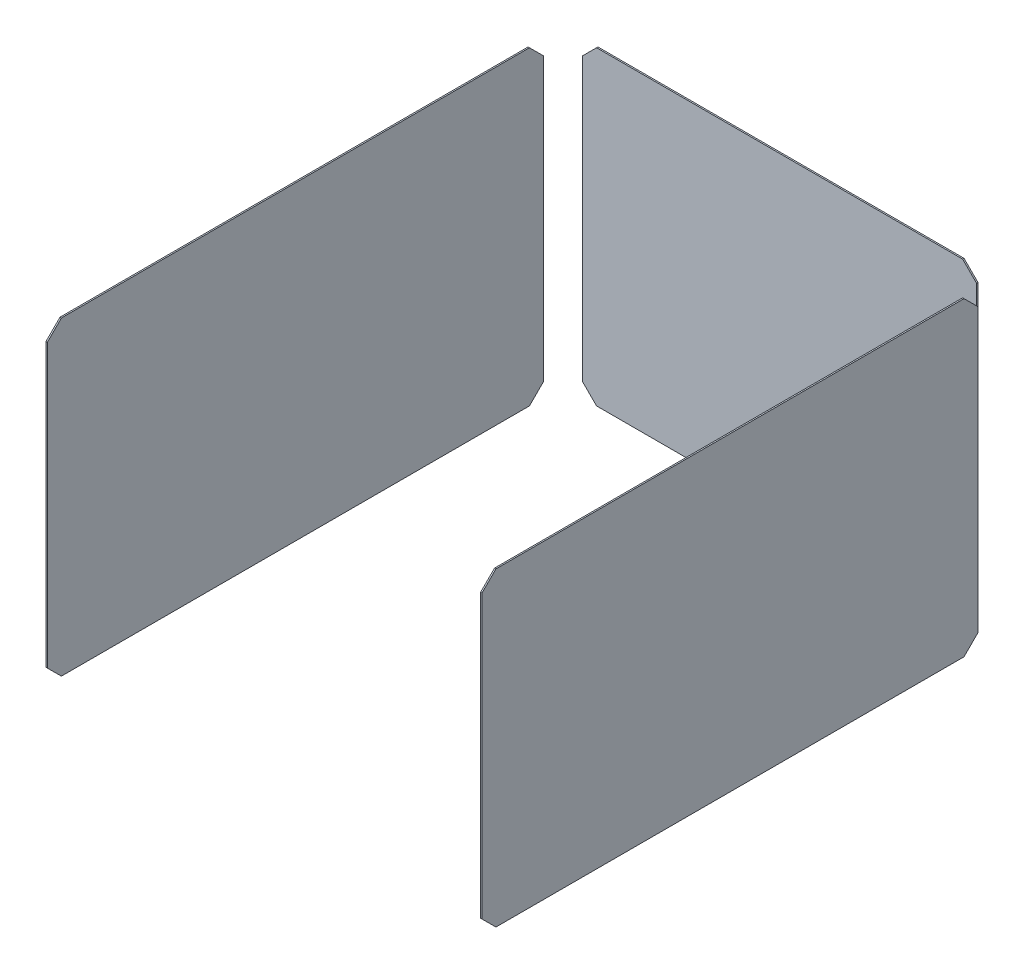
from build123d import *

# Parameters (mm, degrees)
ESQUISSE1_W             = 3120
ESQUISSE1_H             = 2520
ESQUISSE1_W_2           = 3100
ESQUISSE1_H_2           = 2500
EXTRU_MINCE1_DEPTH      = 3700
ESQUISSE3_W             = 3100
ESQUISSE3_H             = 2500
BOSS_EXTRU_1_DEPTH      = 10
ENL_V_MAT_EXTRU_1_DEPTH = 4000
ESQUISSE4_W             = 190.988555417
ESQUISSE4_H             = 256.995888021
ENL_V_MAT_EXTRU_2_DEPTH = 3025.2
CHANFREIN1_SIZE         = 100
CHANFREIN2_SIZE         = 100
CHANFREIN3_SIZE         = 100


with BuildPart() as part:
    # Esquisse1 → Extru.-Mince1 (new body)
    with BuildSketch(Plane.XY):
        with Locations((1550, 1250)):
            Rectangle(ESQUISSE1_W, ESQUISSE1_H)
        with Locations((1550, 1250)):
            Rectangle(ESQUISSE1_W_2, ESQUISSE1_H_2, mode=Mode.SUBTRACT)
    extrude(amount=-EXTRU_MINCE1_DEPTH)

    # Esquisse3 → Boss.-Extru.1 (add)
    with BuildSketch(Plane(origin=(0, 0, -3700), x_dir=(-1, 0, 0), z_dir=(0, 0, -1))):
        with Locations((-1550, 1250)):
            Rectangle(ESQUISSE3_W, ESQUISSE3_H)
    extrude(amount=-BOSS_EXTRU_1_DEPTH)

    # Esquisse2 → Enlèv. mat.-Extru.1 (cut)
    with BuildSketch(Plane.XY):
        Polygon((-60, 2560), (140, 2560), (140, 2500), (2960, 2500), (2960, 2560), (3160, 2560), (3160, 2360), (2960, 2360), (140, 2360), (-60, 2360), align=None)
        Polygon((2960, 140), (140, 140), (-60, 140), (-60, -60), (140, -60), (140, 0), (2960, 0), (2960, -60), (3160, -60), (3160, 140), align=None)
    extrude(amount=-ENL_V_MAT_EXTRU_1_DEPTH, mode=Mode.SUBTRACT)


with BuildPart() as enl_v_mat_extru_1_kept_piece:
    # of the separate pieces the step leaves, the one the design keeps (enl_v_mat_extru_1_pieces_kept)
    add(part.part.solids().sort_by_distance((3110, 140, 0))[0])

    # Esquisse4 → Enlèv. mat.-Extru.2 (cut)
    with BuildSketch(Plane(origin=(0, 2360, 0), x_dir=(1, 0, 0), z_dir=(0, 1, 0))):
        with Locations((44.505722291, 3678.49794401)):
            Rectangle(ESQUISSE4_W, ESQUISSE4_H)
        with Locations((3055.494277708, 3678.49794401)):
            Rectangle(ESQUISSE4_W, ESQUISSE4_H)
    extrude(amount=-ENL_V_MAT_EXTRU_2_DEPTH, mode=Mode.SUBTRACT)


with BuildPart() as enl_v_mat_extru_2_piece_1:
    # of the separate pieces the step leaves, piece 1, a body of its own (enl_v_mat_extru_2_pieces)
    add(enl_v_mat_extru_1_kept_piece.part.solids().sort_by_distance((3110, 140, 0))[0])

    # Chanfrein3
    chanfrein3_edges = [enl_v_mat_extru_2_piece_1.edges().sort_by_distance(p)[0] for p in [
        (3105, 2360, 0),
        (3105, 140, -3550),
        (3105, 140, 0),
        (3105, 2360, -3550),
    ]]
    chamfer(chanfrein3_edges, length=CHANFREIN3_SIZE)


with BuildPart() as enl_v_mat_extru_2_piece_2:
    # of the separate pieces the step leaves, piece 2, a body of its own (enl_v_mat_extru_2_pieces)
    add(enl_v_mat_extru_1_kept_piece.part.solids().sort_by_distance((0, 140, 0))[0])

    # Chanfrein1
    chanfrein1_edges = [enl_v_mat_extru_2_piece_2.edges().sort_by_distance(p)[0] for p in [
        (-5, 140, -3550),
        (-5, 2360, 0),
        (-5, 2360, -3550),
        (-5, 140, 0),
    ]]
    chamfer(chanfrein1_edges, length=CHANFREIN1_SIZE)


with BuildPart() as enl_v_mat_extru_2_piece_3:
    # of the separate pieces the step leaves, piece 3, a body of its own (enl_v_mat_extru_2_pieces)
    add(enl_v_mat_extru_1_kept_piece.part.solids().sort_by_distance((2960, 140, -3690))[0])

    # Chanfrein2
    chanfrein2_edges = [enl_v_mat_extru_2_piece_3.edges().sort_by_distance(p)[0] for p in [
        (140, 140, -3695),
        (2960, 140, -3695),
        (2960, 2360, -3695),
        (140, 2360, -3695),
    ]]
    chamfer(chanfrein2_edges, length=CHANFREIN2_SIZE)


solid = Compound([enl_v_mat_extru_2_piece_1.part, enl_v_mat_extru_2_piece_2.part, enl_v_mat_extru_2_piece_3.part])
